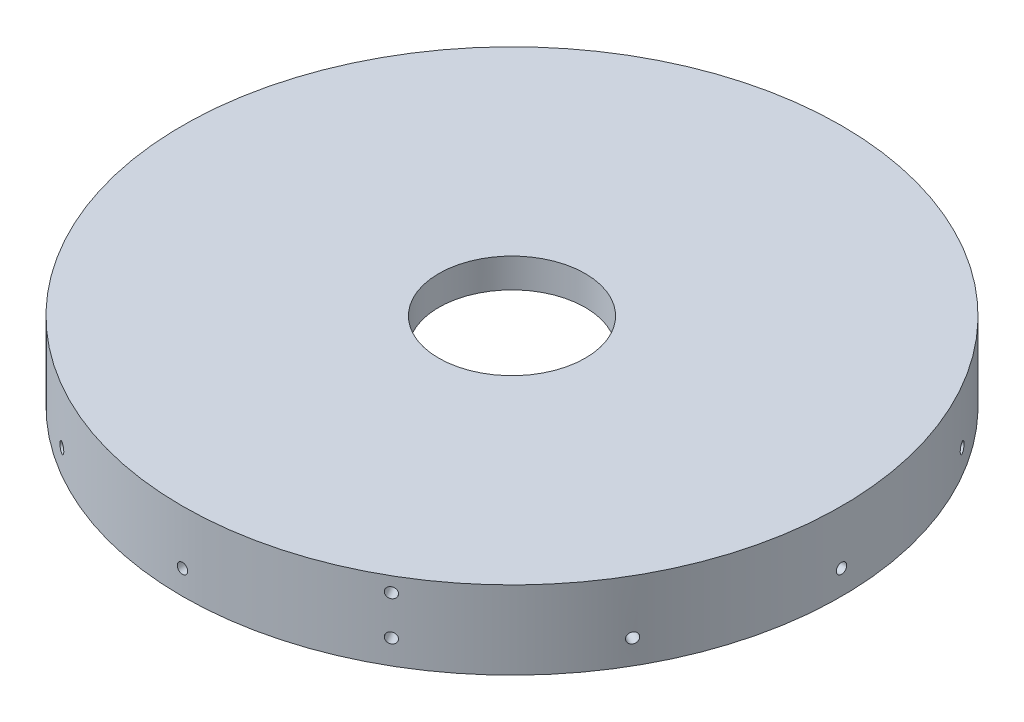
from build123d import *

# Parameters (mm, degrees)
SKETCH1_R           = 85.6615
BOSS_EXTRUDE1_DEPTH = 3.81
SKETCH2_R           = 19.05
CUT_EXTRUDE1_DEPTH  = 7.62
SKETCH4_R           = 85.6615
SKETCH4_R_2         = 79.375
BOSS_EXTRUDE2_DEPTH = 12.7
SKETCH3_R           = 1.35255
CUT_EXTRUDE2_DEPTH  = 15.24
CIRPATTERN1_COUNT   = 3
SKETCH5_R           = 1.35255
CUT_EXTRUDE3_DEPTH  = 17.018
CIRPATTERN2_COUNT   = 12


with BuildPart() as part:
    # Sketch1 → Boss-Extrude1 (new body, symmetric)
    with BuildSketch(Plane(origin=(0, 0, 0), x_dir=(1, 0, 0), z_dir=(0, 1, 0))):
        Circle(SKETCH1_R)
    extrude(amount=BOSS_EXTRUDE1_DEPTH, both=True)

    # Sketch2 → Cut-Extrude1 (cut)
    with BuildSketch(Plane.XZ.offset(3.81)):
        Circle(SKETCH2_R)
    extrude(amount=-CUT_EXTRUDE1_DEPTH, mode=Mode.SUBTRACT)

    # Sketch4 → Boss-Extrude2 (add)
    with BuildSketch(Plane.XZ.offset(3.81)):
        Circle(SKETCH4_R)
        Circle(SKETCH4_R_2, mode=Mode.SUBTRACT)
    extrude(amount=BOSS_EXTRUDE2_DEPTH)

    # Sketch3 → Cut-Extrude2 (cut)
    with BuildSketch(Plane.ZY.offset(85.6615)):
        Circle(SKETCH3_R)
    cut_extrude2 = extrude(amount=-CUT_EXTRUDE2_DEPTH, mode=Mode.SUBTRACT)

    # CirPattern1: Cut-Extrude2 ×3 about axis
    cirpattern1_axis = Axis((0, 0, 0), (0, 1, 0))
    for i in range(1, CIRPATTERN1_COUNT):
        add(cut_extrude2.rotate(cirpattern1_axis, i * 360 / CIRPATTERN1_COUNT), mode=Mode.SUBTRACT)

    # Sketch5 → Cut-Extrude3 (cut)
    with BuildSketch(Plane.ZY.offset(85.6615)):
        with Locations((0, -10.182779697)):
            Circle(SKETCH5_R)
    cut_extrude3 = extrude(amount=-CUT_EXTRUDE3_DEPTH, mode=Mode.SUBTRACT)

    # CirPattern2: Cut-Extrude3 ×12 about axis
    cirpattern2_axis = Axis((0, 3.81, 0), (0, -1, 0))
    for i in range(1, CIRPATTERN2_COUNT):
        add(cut_extrude3.rotate(cirpattern2_axis, i * 360 / CIRPATTERN2_COUNT), mode=Mode.SUBTRACT)


solid = part.part
